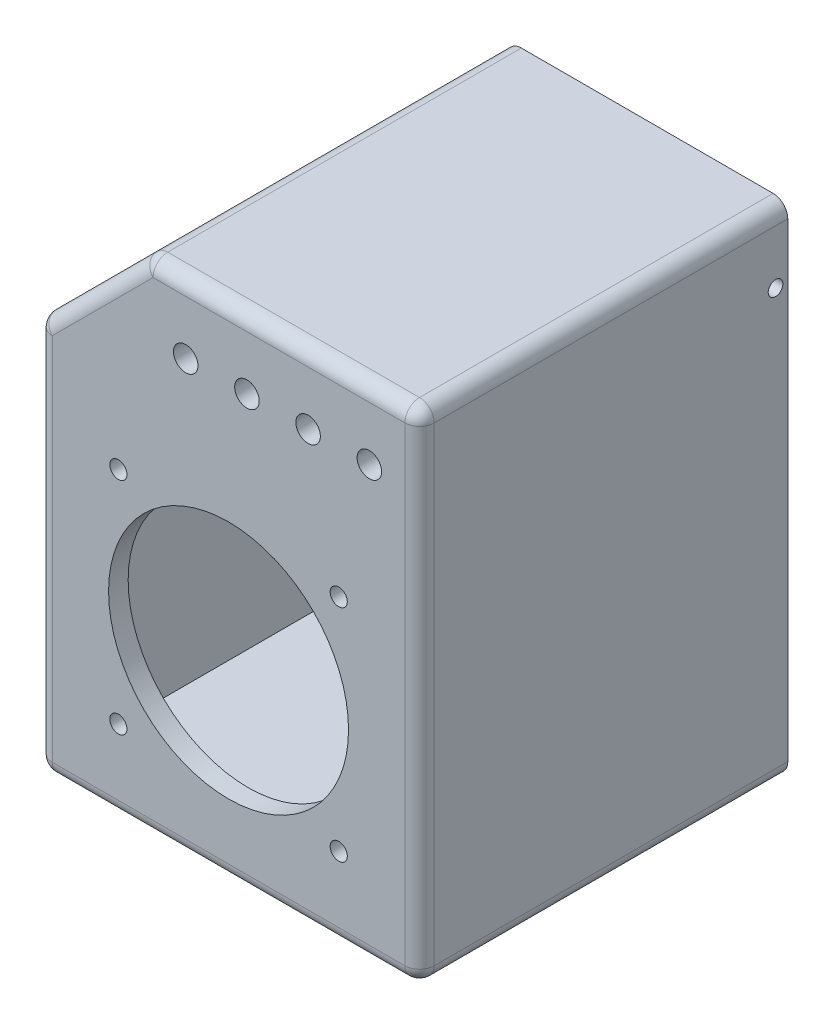
from build123d import *

# Parameters (mm, degrees)
CROQUIS1_W                  = 78
CROQUIS1_H                  = 78
CROQUIS1_R                  = 24.5
SALIENTE_EXTRUIR1_DEPTH     = 4
CROQUIS2_W                  = 78
CROQUIS2_H                  = 78
CROQUIS2_W_2                = 70
CROQUIS2_H_2                = 70
SALIENTE_EXTRUIR2_DEPTH     = 65
CROQUIS3_W                  = 4
CROQUIS3_H                  = 30.5
CORTAR_EXTRUIR1_DEPTH       = 10.5
CROQUIS4_W                  = 5.5
CROQUIS4_H                  = 4
CORTAR_EXTRUIR2_DEPTH       = 4
CROQUIS5_W                  = 10.5
CROQUIS5_H                  = 30.5
CORTAR_EXTRUIR3_DEPTH       = 4
CROQUIS6_W                  = 78
CROQUIS6_H                  = 24
SALIENTE_EXTRUIR3_DEPTH     = 4
SALIENTE_EXTRUIR4_DEPTH     = 65
CROQUIS8_W                  = 70
CROQUIS8_H                  = 4
CORTAR_EXTRUIR4_DEPTH       = 30
CROQUIS9_R                  = 2.5
CORTAR_EXTRUIR5_DEPTH       = 4
CROQUIS11_R                 = 1.75
CORTAR_EXTRUIR7_DEPTH       = 4
SALIENTE_EXTRUIR5_DEPTH     = 6.2
CROQUIS13_R                 = 1.5
CORTAR_EXTRUIR8_DEPTH       = 78
CROQUIS15_R                 = 1.5
CORTAR_EXTRUIR9_DEPTH       = 10
CORTAR_EXTRUIR10_DEPTH      = 72.2
CORTAR_EXTRUIR10_DEPTH_BACK = 5
SALIENTE_EXTRUIR12_DEPTH    = 71.2
CROQUIS20_R                 = 3.7
CROQUIS20_R_2               = 3
CROQUIS20_W                 = 4
CROQUIS20_H                 = 7
CORTAR_EXTRUIR11_DEPTH      = 4
CROQUIS21_W                 = 8
CROQUIS21_H                 = 13
CORTAR_EXTRUIR12_DEPTH      = 1.5
CROQUIS22_R                 = 1.5
CORTAR_EXTRUIR13_DEPTH      = 4
REDONDEO1_R                 = 3


with BuildPart() as part:
    # Croquis1 → Saliente-Extruir1 (new body)
    with BuildSketch(Plane.XY):
        Rectangle(CROQUIS1_W, CROQUIS1_H)
        Circle(CROQUIS1_R, mode=Mode.SUBTRACT)
    extrude(amount=SALIENTE_EXTRUIR1_DEPTH)

    # Croquis2 → Saliente-Extruir2 (add)
    with BuildSketch(Plane(origin=(0, 0, 0), x_dir=(-1, 0, 0), z_dir=(0, 0, -1))):
        Rectangle(CROQUIS2_W, CROQUIS2_H)
        Rectangle(CROQUIS2_W_2, CROQUIS2_H_2, mode=Mode.SUBTRACT)
    extrude(amount=SALIENTE_EXTRUIR2_DEPTH)

    # Croquis3 → Cortar-Extruir1 (cut)
    with BuildSketch(Plane(origin=(0, 0, -65), x_dir=(-1, 0, 0), z_dir=(0, 0, -1))):
        with Locations((37, -11.75)):
            Rectangle(CROQUIS3_W, CROQUIS3_H)
    extrude(amount=-CORTAR_EXTRUIR1_DEPTH, mode=Mode.SUBTRACT)

    # Croquis4 → Cortar-Extruir2 (cut)
    with BuildSketch(Plane.ZY.offset(39)):
        with Locations((-47.75, -4)):
            Rectangle(CROQUIS4_W, CROQUIS4_H)
        with Locations((-47.75, -19.5)):
            Rectangle(CROQUIS4_W, CROQUIS4_H)
    extrude(amount=-CORTAR_EXTRUIR2_DEPTH, mode=Mode.SUBTRACT)

    # Croquis5 → Cortar-Extruir3 (cut)
    with BuildSketch(Plane.ZY.offset(39)):
        with Locations((-55.75, -11.75)):
            Rectangle(CROQUIS5_W, CROQUIS5_H)
    extrude(amount=-CORTAR_EXTRUIR3_DEPTH, mode=Mode.SUBTRACT)

    # Croquis6 → Saliente-Extruir3 (add)
    with BuildSketch(Plane.XY.offset(4)):
        with Locations((0, 51)):
            Rectangle(CROQUIS6_W, CROQUIS6_H)
    extrude(amount=-SALIENTE_EXTRUIR3_DEPTH)

    # Croquis7 → Saliente-Extruir4 (add)
    with BuildSketch(Plane(origin=(0, 0, 0), x_dir=(-1, 0, 0), z_dir=(0, 0, -1))):
        Polygon((-39, 39), (-39, 63), (39, 63), (39, 39), (35, 39), (35, 59), (-35, 59), (-35, 39), align=None)
    extrude(amount=SALIENTE_EXTRUIR4_DEPTH)

    # Croquis8 → Cortar-Extruir4 (cut)
    with BuildSketch(Plane(origin=(0, 0, -65), x_dir=(-1, 0, 0), z_dir=(0, 0, -1))):
        with Locations((0, 37)):
            Rectangle(CROQUIS8_W, CROQUIS8_H)
    extrude(amount=-CORTAR_EXTRUIR4_DEPTH, mode=Mode.SUBTRACT)

    # Croquis9 → Cortar-Extruir5 (cut)
    with BuildSketch(Plane(origin=(0, 0, 0), x_dir=(-1, 0, 0), z_dir=(0, 0, -1))):
        with Locations((-16.25, 49)):
            Circle(CROQUIS9_R)
        with Locations((-3.75, 49)):
            Circle(CROQUIS9_R)
        with Locations((8.75, 49)):
            Circle(CROQUIS9_R)
        with Locations((-28.75, 49)):
            Circle(CROQUIS9_R)
    extrude(amount=-CORTAR_EXTRUIR5_DEPTH, mode=Mode.SUBTRACT)

    # Croquis11 → Cortar-Extruir7 (cut)
    with BuildSketch(Plane.XY.offset(4)):
        with Locations((-22.5, 22.5)):
            Circle(CROQUIS11_R)
        with Locations((22.5, 22.5)):
            Circle(CROQUIS11_R)
        with Locations((22.5, -22.5)):
            Circle(CROQUIS11_R)
        with Locations((-22.5, -22.5)):
            Circle(CROQUIS11_R)
    extrude(amount=-CORTAR_EXTRUIR7_DEPTH, mode=Mode.SUBTRACT)

    # Croquis12 → Saliente-Extruir5 (add)
    with BuildSketch(Plane(origin=(0, 0, -65), x_dir=(-1, 0, 0), z_dir=(0, 0, -1))):
        Polygon((39, 3.5), (39, 63), (-39, 63), (-39, -39), (39, -39), (39, -27), (35, -27), (35, -35), (-35, -35), (-35, 59), (35, 59), (35, 3.5), align=None)
    extrude(amount=SALIENTE_EXTRUIR5_DEPTH)

    # Croquis13 → Cortar-Extruir8 (cut)
    with BuildSketch(Plane.ZY.offset(39)):
        with Locations((-68.7, 49)):
            Circle(CROQUIS13_R)
    extrude(amount=-CORTAR_EXTRUIR8_DEPTH, mode=Mode.SUBTRACT)

    # Croquis15 → Cortar-Extruir9 (cut)
    with BuildSketch(Plane.XZ.offset(39)):
        with Locations((0, -68.7)):
            Circle(CROQUIS15_R)
    extrude(amount=-CORTAR_EXTRUIR9_DEPTH, mode=Mode.SUBTRACT)

    # Croquis18 → Cortar-Extruir10 (cut, two sides)
    with BuildSketch(Plane(origin=(0, 0, 0), x_dir=(-1, 0, 0), z_dir=(0, 0, -1))) as cortar_extruir10_sk:
        Polygon((37.828427125, 41.828427125), (46.180842651, 33.476011598), (52.654514268, 70.809075829), (7.06091393, 72.59594032), align=None)
    extrude(amount=CORTAR_EXTRUIR10_DEPTH, mode=Mode.SUBTRACT)
    extrude(cortar_extruir10_sk.sketch, amount=-CORTAR_EXTRUIR10_DEPTH_BACK, mode=Mode.SUBTRACT)

    # Croquis19 → Saliente-Extruir12 (add)
    with BuildSketch(Plane(origin=(0, 0, 0), x_dir=(-1, 0, 0), z_dir=(0, 0, -1))):
        Polygon((35, 39), (15, 59), (20.656854249, 59), (35, 44.656854249), align=None)
    extrude(amount=SALIENTE_EXTRUIR12_DEPTH)

    # Croquis20 → Cortar-Extruir11 (cut)
    with BuildSketch(Plane(origin=(-39.828427125, 39.828427125, 0), x_dir=(0, 0, 1), z_dir=(-0.707106781, 0.707106781, 0))):
        with Locations((-21, 18.970562748)):
            Circle(CROQUIS20_R)
        with Locations((-36, 18.970562748)):
            Circle(CROQUIS20_R)
        with Locations((-56, 18.970562748)):
            Circle(CROQUIS20_R_2)
        with Locations((-6, 18.970562748)):
            Rectangle(CROQUIS20_W, CROQUIS20_H)
    extrude(amount=-CORTAR_EXTRUIR11_DEPTH, mode=Mode.SUBTRACT)

    # Croquis21 → Cortar-Extruir12 (cut)
    with BuildSketch(Plane(origin=(-37, 37, 0), x_dir=(0, 0, -1), z_dir=(0.707106781, -0.707106781, 0))):
        with Locations((56, 18.970562748)):
            Rectangle(CROQUIS21_W, CROQUIS21_H)
    extrude(amount=-CORTAR_EXTRUIR12_DEPTH, mode=Mode.SUBTRACT)

    # Croquis22 → Cortar-Extruir13 (cut)
    with BuildSketch(Plane(origin=(-39.828427125, 39.828427125, 0), x_dir=(0, 0, 1), z_dir=(-0.707106781, 0.707106781, 0))):
        with Locations((-68.7, 16.970562748)):
            Circle(CROQUIS22_R)
    extrude(amount=-CORTAR_EXTRUIR13_DEPTH, mode=Mode.SUBTRACT)

    # Redondeo1
    redondeo1_edges = [part.edges().sort_by_distance(p)[0] for p in [
        (39, 63, -33.6),
        (11.171572875, 63, 4),
        (39, -39, -33.6),
        (-39, -39, -33.6),
        (-39, 0.828427125, 4),
        (-27.828427125, 51.828427125, 4),
        (-39, 40.656854249, -33.6),
        (-16.656854249, 63, -33.6),
        (0, -39, 4),
        (39, 12, 4),
    ]]
    fillet(redondeo1_edges, radius=REDONDEO1_R)


solid = part.part
